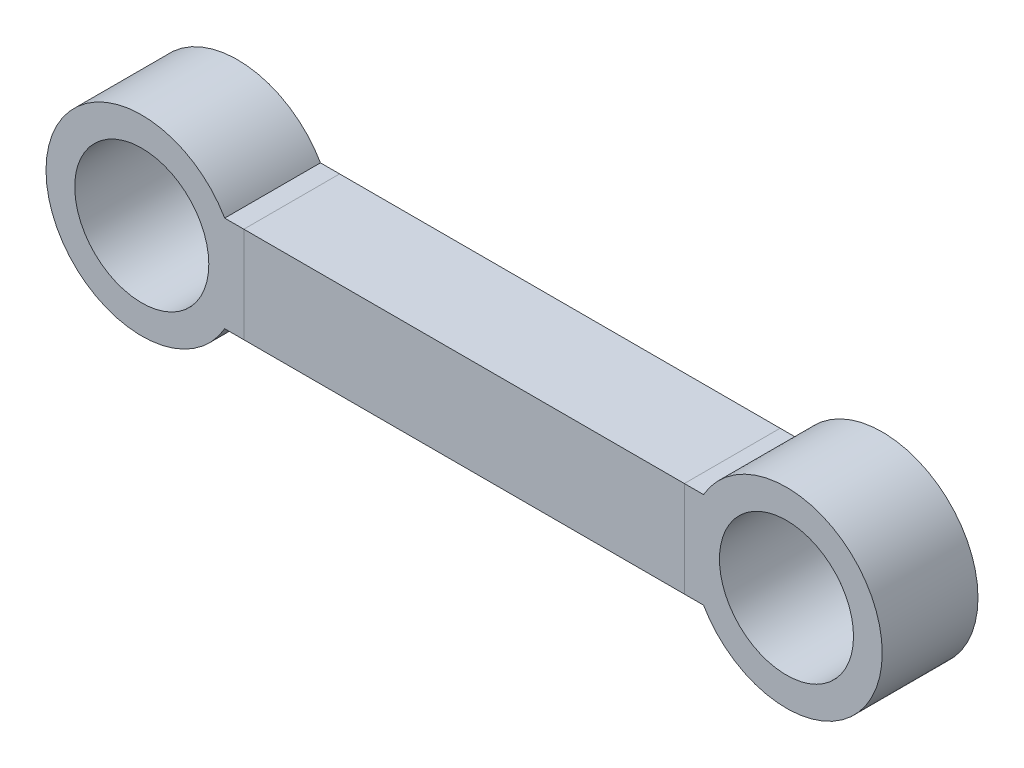
from build123d import *

# Parameters (mm, degrees)
SKETCH1_R             = 7
BOSS_EXTRUDE1_DEPTH   = 10
BOSS_EXTRUDE1_2_DEPTH = 10
SKETCH1_3_W           = 46
SKETCH1_3_H           = 10
BOSS_EXTRUDE2_DEPTH   = 10


with BuildPart() as part:
    # Sketch1 → Boss-Extrude1 (new body)
    with BuildSketch(Plane.XY):
        with BuildLine():
            Line((-23, 5), (-25, 5))
            ThreePointArc((-25, 5), (-43.660254038, 0), (-25, -5))
            Line((-25, -5), (-23, -5))
            Line((-23, -5), (-23, 5))
        make_face()
        with Locations((-33.660254038, 0)):
            Circle(SKETCH1_R, mode=Mode.SUBTRACT)
    extrude(amount=BOSS_EXTRUDE1_DEPTH)


with BuildPart() as body_2:
    # Sketch1 → Boss-Extrude1 2 (new body)
    with BuildSketch(Plane.XY):
        with BuildLine():
            Line((25, 5), (23, 5))
            Line((23, 5), (23, -5))
            Line((23, -5), (25, -5))
            ThreePointArc((25, -5), (43.660254038, 0), (25, 5))
        make_face()
        with Locations((33.660254038, 0)):
            Circle(SKETCH1_R, mode=Mode.SUBTRACT)
    extrude(amount=BOSS_EXTRUDE1_2_DEPTH)


with BuildPart() as body_3:
    # Sketch1_3 → Boss-Extrude2 (new body)
    with BuildSketch(Plane.XY):
        Rectangle(SKETCH1_3_W, SKETCH1_3_H)
    extrude(amount=BOSS_EXTRUDE2_DEPTH)


solid = Compound([part.part, body_2.part, body_3.part])
